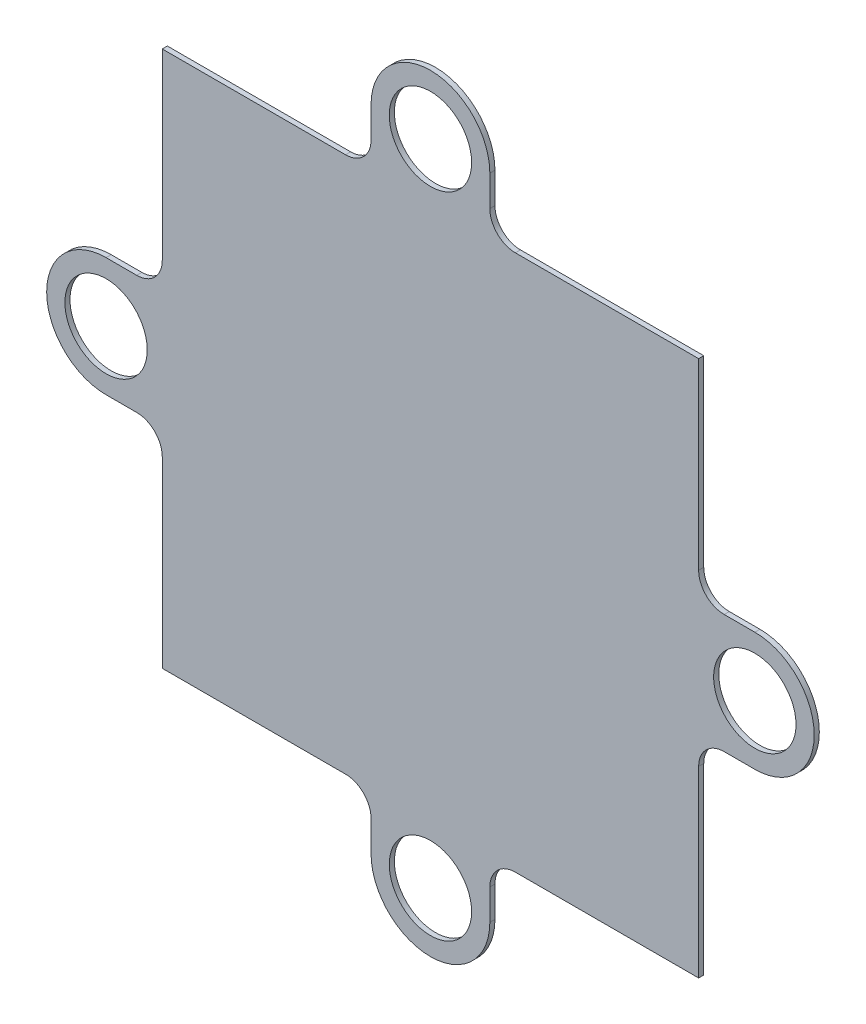
from build123d import *

# Parameters (mm, degrees)
SKETCH1_R           = 3.225
BOSS_EXTRUDE1_DEPTH = 0.4


with BuildPart() as part:
    # Sketch1 → Boss-Extrude1 (new body)
    with BuildSketch(Plane.XY):
        with BuildLine():
            ThreePointArc((4.65, 25.4), (0, 30.05), (-4.65, 25.4))
            Line((-4.65, 25.4), (-4.65, 23))
            ThreePointArc((-4.65, 23), (-5.235786438, 21.585786438), (-6.65, 21))
            Line((-6.65, 21), (-8.759132098, 21))
            Line((-8.759132098, 21), (-21, 21))
            Line((-21, 21), (-21, 7.133487824))
            Line((-21, 7.133487824), (-21, 6.65))
            ThreePointArc((-21, 6.65), (-21.585786438, 5.235786438), (-23, 4.65))
            Line((-23, 4.65), (-25.4, 4.65))
            ThreePointArc((-25.4, 4.65), (-30.05, 0), (-25.4, -4.65))
            Line((-25.4, -4.65), (-23, -4.65))
            ThreePointArc((-23, -4.65), (-21.585786438, -5.235786438), (-21, -6.65))
            Line((-21, -6.65), (-21, -8.759132098))
            Line((-21, -8.759132098), (-21, -21))
            Line((-21, -21), (-7.133487824, -21))
            Line((-7.133487824, -21), (-6.65, -21))
            ThreePointArc((-6.65, -21), (-5.235786438, -21.585786438), (-4.65, -23))
            Line((-4.65, -23), (-4.65, -25.4))
            ThreePointArc((-4.65, -25.4), (0, -30.05), (4.65, -25.4))
            Line((4.65, -25.4), (4.65, -23))
            ThreePointArc((4.65, -23), (5.235786438, -21.585786438), (6.65, -21))
            Line((6.65, -21), (8.759132098, -21))
            Line((8.759132098, -21), (21, -21))
            Line((21, -21), (21, -7.133487824))
            Line((21, -7.133487824), (21, -6.65))
            ThreePointArc((21, -6.65), (21.585786438, -5.235786438), (23, -4.65))
            Line((23, -4.65), (25.4, -4.65))
            ThreePointArc((25.4, -4.65), (30.05, 0), (25.4, 4.65))
            Line((25.4, 4.65), (23, 4.65))
            ThreePointArc((23, 4.65), (21.585786438, 5.235786438), (21, 6.65))
            Line((21, 6.65), (21, 8.759132098))
            Line((21, 8.759132098), (21, 21))
            Line((21, 21), (7.133487824, 21))
            Line((7.133487824, 21), (6.65, 21))
            ThreePointArc((6.65, 21), (5.235786438, 21.585786438), (4.65, 23))
            Line((4.65, 23), (4.65, 25.4))
        make_face()
        with Locations((0, -25.4)):
            Circle(SKETCH1_R, mode=Mode.SUBTRACT)
        with Locations((25.4, 0)):
            Circle(SKETCH1_R, mode=Mode.SUBTRACT)
        with Locations((-25.4, 0)):
            Circle(SKETCH1_R, mode=Mode.SUBTRACT)
        with Locations((0, 25.4)):
            Circle(SKETCH1_R, mode=Mode.SUBTRACT)
    extrude(amount=BOSS_EXTRUDE1_DEPTH)


solid = part.part
